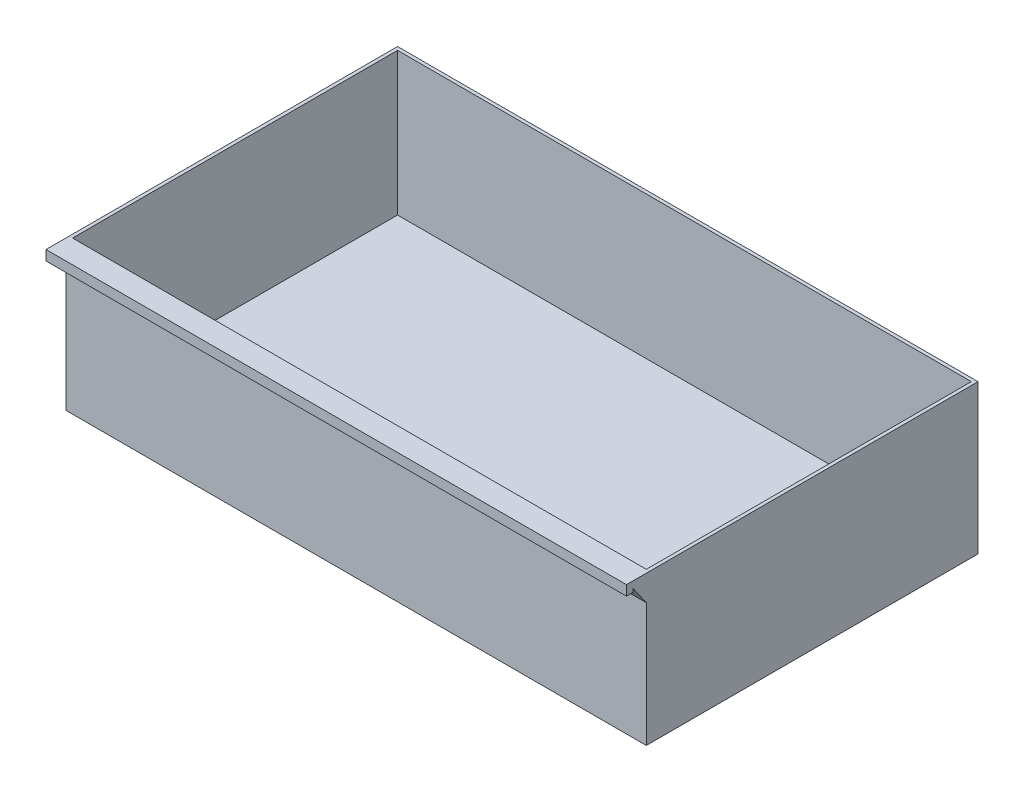
from build123d import *

# Parameters (mm, degrees)
SKETCH3_W          = 222.25
SKETCH3_H          = 127
LOWER_DRAWER_DEPTH = 57.15
SKETCH6_W          = 219.71
SKETCH6_H          = 124.46
CUT_EXTRUDE1_DEPTH = 54.61
HANDLE_DEPTH       = 222.25


with BuildPart() as part:
    # Sketch3 → lower drawer (new body)
    with BuildSketch(Plane(origin=(0, 0, 0), x_dir=(1, 0, 0), z_dir=(0, 1, 0))):
        Rectangle(SKETCH3_W, SKETCH3_H)
    extrude(amount=LOWER_DRAWER_DEPTH)

    # Sketch6 → Cut-Extrude1 (cut)
    with BuildSketch(Plane(origin=(0, 57.15, 0), x_dir=(1, 0, 0), z_dir=(0, 1, 0))):
        Rectangle(SKETCH6_W, SKETCH6_H)
    extrude(amount=-CUT_EXTRUDE1_DEPTH, mode=Mode.SUBTRACT)

    # Sketch10 → handle (add)
    with BuildSketch(Plane.ZY.offset(111.125)):
        Polygon((63.5, 57.15), (71.12, 57.15), (71.12, 53.34), (68.58, 53.34), (68.58, 54.61), (63.5, 47.355008126), align=None)
    extrude(amount=-HANDLE_DEPTH)


solid = part.part
